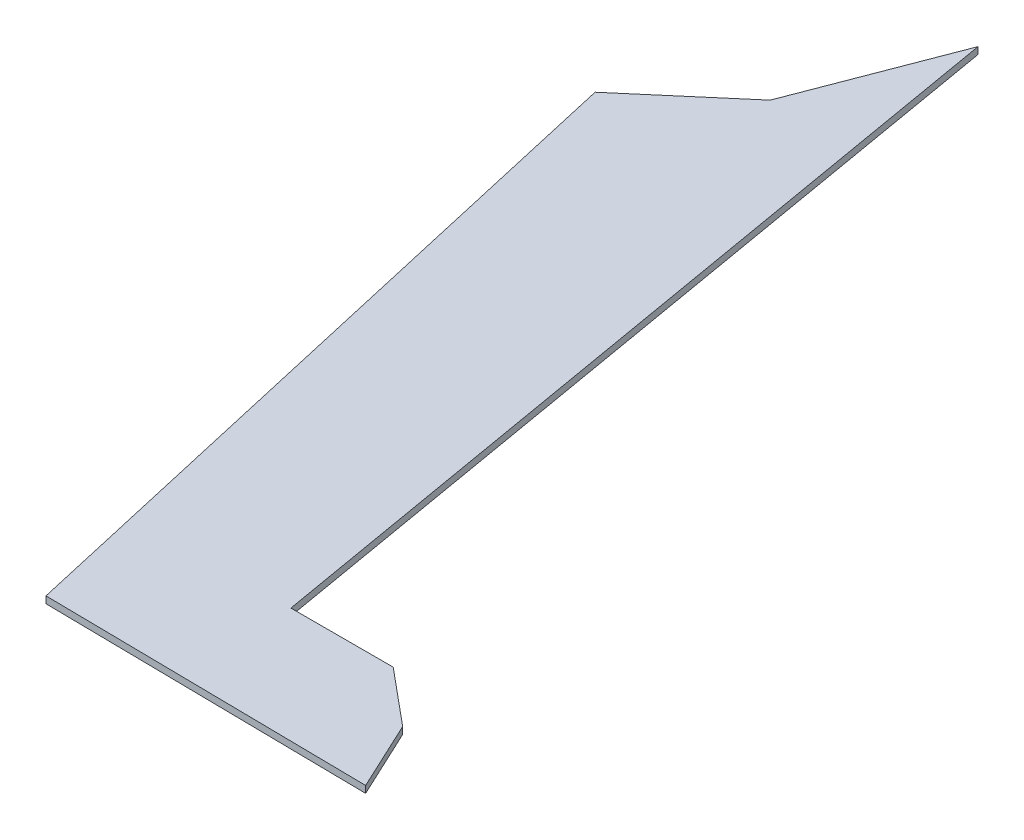
from build123d import *

# Parameters (mm, degrees)
BOSS_EXTRU_1_DEPTH = 2


with BuildPart() as part:
    # Esquisse1 → Boss.-Extru.1 (new body)
    with BuildSketch(Plane(origin=(0, 0, 0), x_dir=(1, 0, 0), z_dir=(0, 1, 0))):
        Polygon((68.510329691, 32.56595571), (38.726340319, 32.56595571), (-2.812156702, 274.135584624), (-19.566235118, 230.38708924), (-47.052202514, 206.901229399), (0, 0), (94.326137199, -1.276034328), (84.861154742, 18.976731259), align=None)
    extrude(amount=BOSS_EXTRU_1_DEPTH)


solid = part.part
